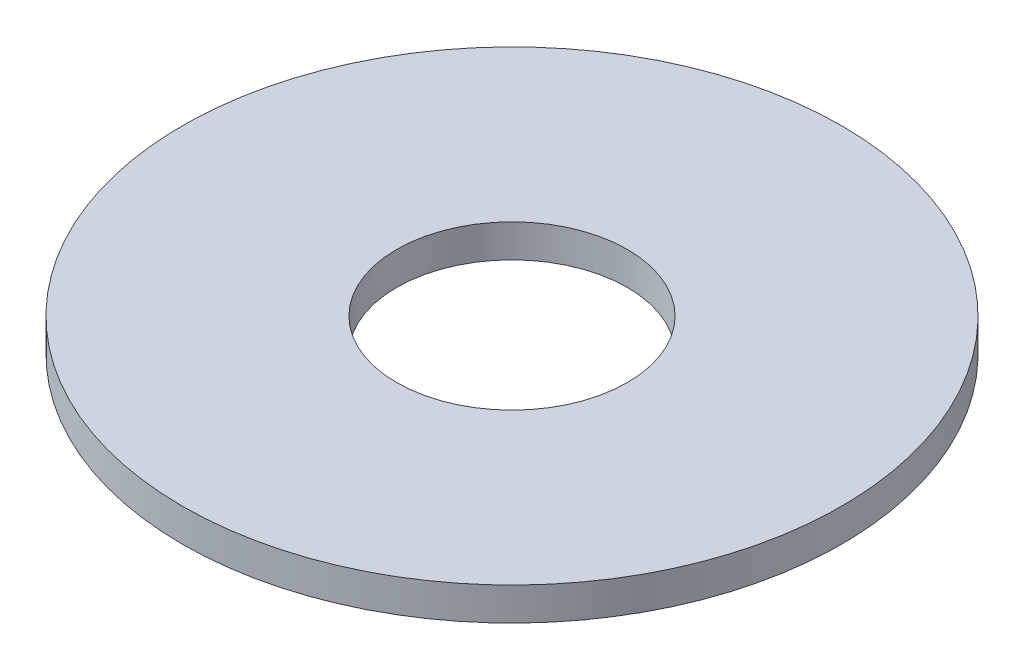
from build123d import *

# Parameters (mm, degrees)
SKETCH1_R           = 50
SKETCH1_R_2         = 17.5
BOSS_EXTRUDE1_DEPTH = 5


with BuildPart() as part:
    # Sketch1 → Boss-Extrude1 (new body)
    with BuildSketch(Plane(origin=(0, 0, 0), x_dir=(1, 0, 0), z_dir=(0, 1, 0))):
        Circle(SKETCH1_R)
        Circle(SKETCH1_R_2, mode=Mode.SUBTRACT)
    extrude(amount=BOSS_EXTRUDE1_DEPTH)


solid = part.part
